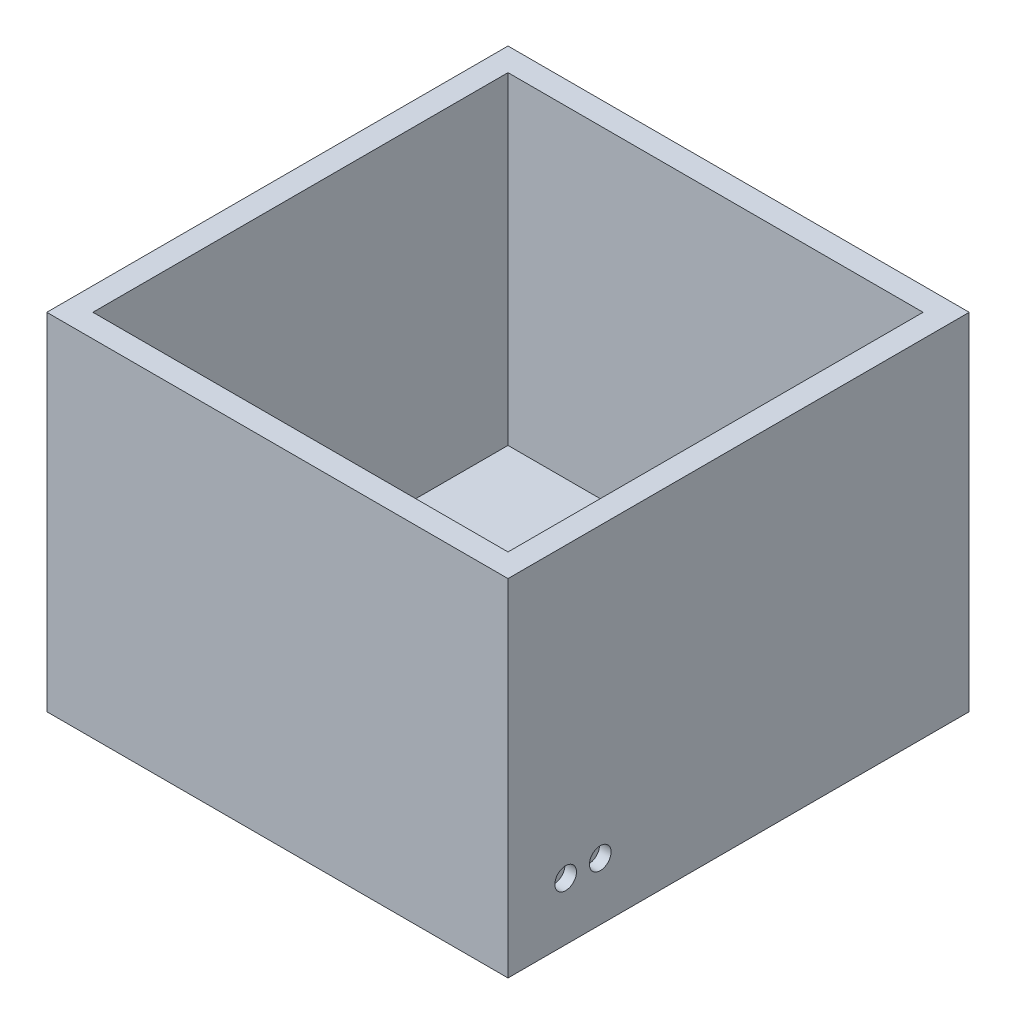
from build123d import *

# Parameters (mm, degrees)
SKETCH1_W           = 101.6
SKETCH1_H           = 101.6
BOSS_EXTRUDE1_DEPTH = 76.2
SKETCH2_W           = 91.44
SKETCH2_H           = 91.44
CUT_EXTRUDE1_DEPTH  = 71.12
SKETCH3_R           = 2.38125
CUT_EXTRUDE2_DEPTH  = 2.54
SKETCH4_R           = 0.635
CUT_EXTRUDE3_DEPTH  = 2.54
SKETCH6_R           = 2.38125
CUT_EXTRUDE5_DEPTH  = 2.54
SKETCH8_R           = 0.635
CUT_EXTRUDE7_DEPTH  = 2.54


with BuildPart() as part:
    # Sketch1 → Boss-Extrude1 (new body)
    with BuildSketch(Plane(origin=(0, 0, 0), x_dir=(1, 0, 0), z_dir=(0, 1, 0))):
        with Locations((-46.892307692, 7.947401247)):
            Rectangle(SKETCH1_W, SKETCH1_H)
    extrude(amount=BOSS_EXTRUDE1_DEPTH)

    # Sketch2 → Cut-Extrude1 (cut)
    with BuildSketch(Plane(origin=(0, 76.2, 0), x_dir=(1, 0, 0), z_dir=(0, 1, 0))):
        with Locations((-46.892307692, 7.947401247)):
            Rectangle(SKETCH2_W, SKETCH2_H)
    extrude(amount=-CUT_EXTRUDE1_DEPTH, mode=Mode.SUBTRACT)

    # Sketch3 → Cut-Extrude2 (cut)
    with BuildSketch(Plane(origin=(3.907692308, 0, 0), x_dir=(0, 0, -1), z_dir=(1, 0, 0))):
        with Locations((-30.152598753, 12.7)):
            Circle(SKETCH3_R)
    extrude(amount=-CUT_EXTRUDE2_DEPTH, mode=Mode.SUBTRACT)

    # Sketch4 → Cut-Extrude3 (cut)
    with BuildSketch(Plane(origin=(1.367692308, 0, 0), x_dir=(0, 0, -1), z_dir=(1, 0, 0))):
        with Locations((-31.42844237, 12.756924018)):
            Circle(SKETCH4_R)
        with Locations((-28.88844237, 12.859462566)):
            Circle(SKETCH4_R)
    extrude(amount=-CUT_EXTRUDE3_DEPTH, mode=Mode.SUBTRACT)

    # Sketch6 → Cut-Extrude5 (cut)
    with BuildSketch(Plane(origin=(3.907692308, 0, 0), x_dir=(0, 0, -1), z_dir=(1, 0, 0))):
        with Locations((-22.532598753, 12.7)):
            Circle(SKETCH6_R)
    extrude(amount=-CUT_EXTRUDE5_DEPTH, mode=Mode.SUBTRACT)

    # Sketch8 → Cut-Extrude7 (cut)
    with BuildSketch(Plane(origin=(1.367692308, 0, 0), x_dir=(0, 0, -1), z_dir=(1, 0, 0))):
        with Locations((-23.822454546, 12.843688335)):
            Circle(SKETCH8_R)
        with Locations((-21.299543609, 12.843688335)):
            Circle(SKETCH8_R)
    extrude(amount=-CUT_EXTRUDE7_DEPTH, mode=Mode.SUBTRACT)


solid = part.part
